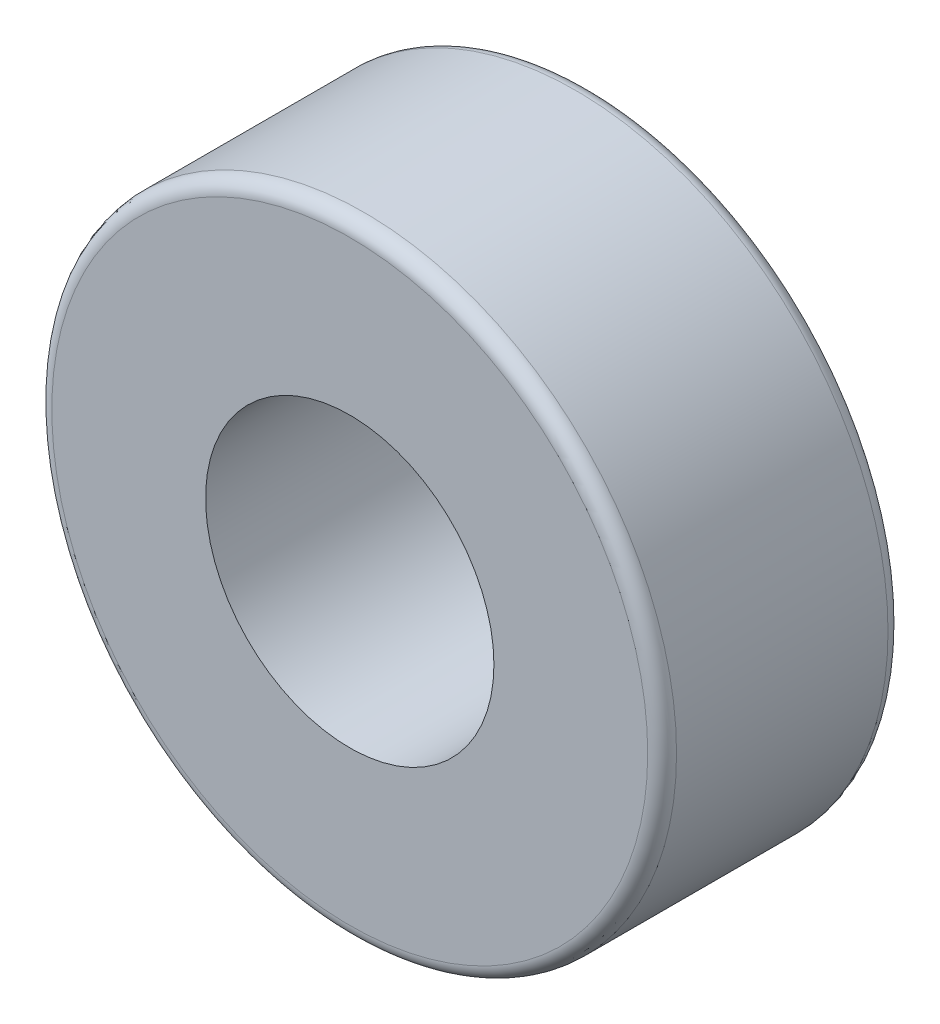
from build123d import *

# Parameters (mm, degrees)
SKETCH1_R           = 6.5
SKETCH1_R_2         = 3
BOSS_EXTRUDE1_DEPTH = 5
FILLET1_R           = 0.3


with BuildPart() as part:
    # Sketch1 → Boss-Extrude1 (new body)
    with BuildSketch(Plane.XY):
        Circle(SKETCH1_R)
        Circle(SKETCH1_R_2, mode=Mode.SUBTRACT)
    extrude(amount=BOSS_EXTRUDE1_DEPTH)

    # Fillet1
    fillet1_edges = [part.edges().sort_by_distance(p)[0] for p in [
        (-6.5, 0, 0),
        (-6.5, 0, 5),
    ]]
    fillet(fillet1_edges, radius=FILLET1_R)


solid = part.part
